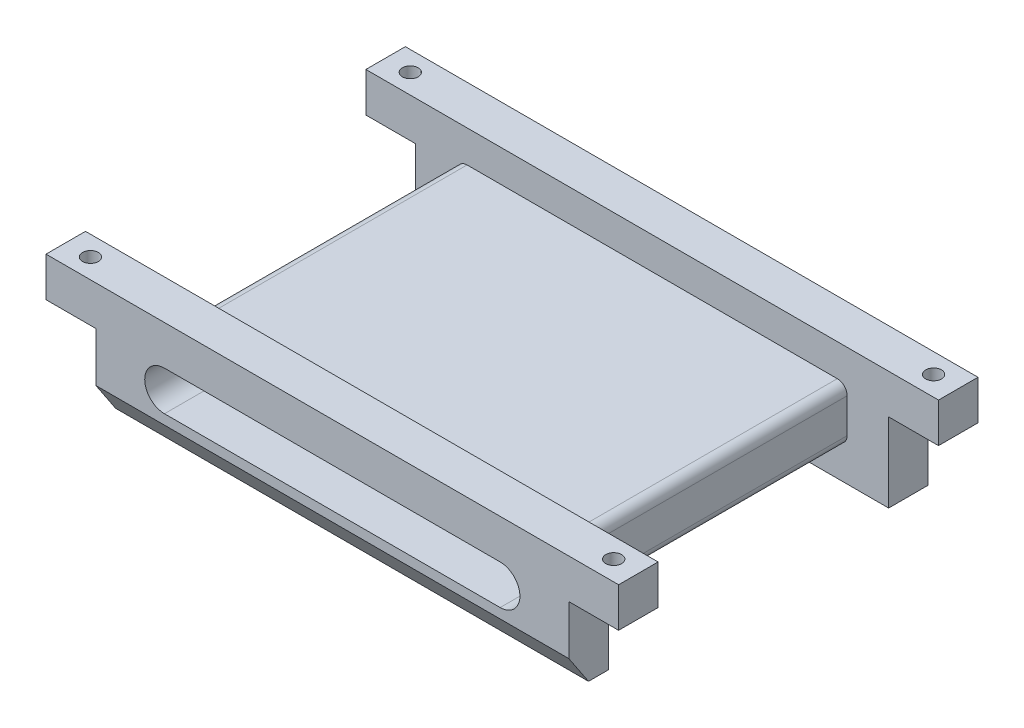
from build123d import *

# Parameters (mm, degrees)
BOSS_EXTRUDE1_DEPTH             = 36.4
CUT_EXTRUDE1_START              = -4
SKETCH2_OUTSIDE_W               = 73.904
SKETCH2_OUTSIDE_H               = 27.904
CUT_EXTRUDE1_DEPTH              = 28.4
CHAMFER1_SIZE                   = 2
CHAMFER1_SIZE2                  = 3
TAP_DRILL_FOR_M2X0_4_TAP1_D     = 1.6
TAP_DRILL_FOR_M2X0_4_TAP1_DEPTH = 4


with BuildPart() as part:
    # Sketch1 → Boss-Extrude1 (new body)
    with BuildSketch(Plane.XY):
        Polygon((0, 12), (58, 12), (58, 8), (52.95, 8), (52.95, 0), (5.05, 0), (5.05, 8), (0, 8), align=None)
        with BuildLine():
            Line((12, 8), (46, 8))
            ThreePointArc((46, 8), (48, 6), (46, 4))
            Line((46, 4), (12, 4))
            ThreePointArc((12, 4), (10, 6), (12, 8))
        make_face(mode=Mode.SUBTRACT)
    extrude(amount=BOSS_EXTRUDE1_DEPTH)

    # Sketch2 outside → Cut-Extrude1 (cut)
    with BuildSketch(Plane.XY.offset(36.4).offset(CUT_EXTRUDE1_START)):
        with Locations((29, 6)):
            Rectangle(SKETCH2_OUTSIDE_W, SKETCH2_OUTSIDE_H)
        with BuildLine():
            Line((10.25, 8.75), (47.75, 8.75))
            ThreePointArc((47.75, 8.75), (48.457106781, 8.457106781), (48.75, 7.75))
            Line((48.75, 7.75), (48.75, 4.25))
            ThreePointArc((48.75, 4.25), (48.457106781, 3.542893219), (47.75, 3.25))
            Line((47.75, 3.25), (10.25, 3.25))
            ThreePointArc((10.25, 3.25), (9.542893219, 3.542893219), (9.25, 4.25))
            Line((9.25, 4.25), (9.25, 7.75))
            ThreePointArc((9.25, 7.75), (9.542893219, 8.457106781), (10.25, 8.75))
        make_face(mode=Mode.SUBTRACT)
    extrude(amount=-CUT_EXTRUDE1_DEPTH, mode=Mode.SUBTRACT)

    # Chamfer1
    chamfer1_edges = [part.edges().sort_by_distance(p)[0] for p in [
        (29, 0, 36.4),
    ]]
    chamfer1_side = [part.faces().sort_by_distance(p)[0] for p in [
        (29, 0, 34.4),
    ]]
    chamfer(chamfer1_edges, length=CHAMFER1_SIZE, length2=CHAMFER1_SIZE2, reference=chamfer1_side[0])

    # Tap Drill for M2x0.4 Tap1
    with Locations(Plane(origin=(0, 12, 0), x_dir=(1, 0, 0), z_dir=(0, 1, 0))):
        with Locations((2.5, -2), (55.5, -2), (55.5, -34.4), (2.5, -34.4)):
            Hole(TAP_DRILL_FOR_M2X0_4_TAP1_D / 2, depth=TAP_DRILL_FOR_M2X0_4_TAP1_DEPTH)


solid = part.part
